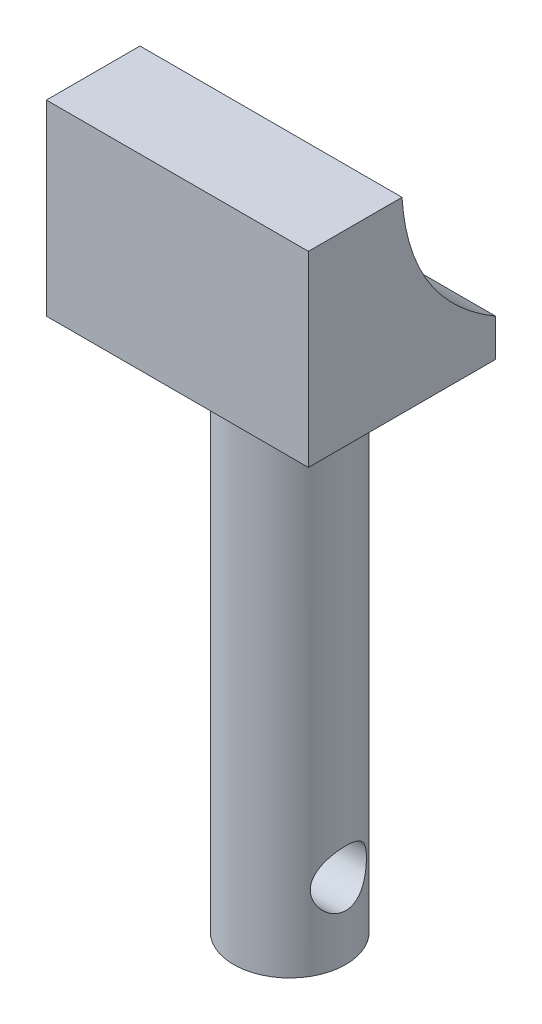
from build123d import *

# Parameters (mm, degrees)
SKETCH1_W             = 7
SKETCH1_H             = 5
BOSS_EXTRUDE1_DEPTH   = 5
CUT_EXTRUDE1_DEPTH    = 7
SKETCH4_R             = 1.5
BOSS_EXTRUDE3_DEPTH   = 14
F_1_5MM_DOWEL_HOLE2_D = 1.5


with BuildPart() as part:
    # Sketch1 → Boss-Extrude1 (new body)
    with BuildSketch(Plane.XY):
        with Locations((-1.19986884, 2.172533045)):
            Rectangle(SKETCH1_W, SKETCH1_H)
    extrude(amount=BOSS_EXTRUDE1_DEPTH)

    # Sketch2 → Cut-Extrude1 (cut)
    with BuildSketch(Plane.ZY.offset(4.69986884)):
        with BuildLine():
            Line((2.5, 4.672533045), (0, 4.672533045))
            Line((0, 4.672533045), (0, 0.672533045))
            add(Edge.make_bspline(
                [(0, 0.672533045), (2.331009943, 2.039673482), (2.5, 4.672533045)],
                knots=[0, 0, 0, 1, 1, 1], degree=2))
        make_face()
    extrude(amount=-CUT_EXTRUDE1_DEPTH, mode=Mode.SUBTRACT)

    # Sketch4 → Boss-Extrude3 (add)
    with BuildSketch(Plane.XZ.offset(0.327466955)):
        with Locations((-1.19986884, 2)):
            Circle(SKETCH4_R)
    extrude(amount=BOSS_EXTRUDE3_DEPTH)

    # Ø1.5mm Dowel Hole2 (through all)
    with Locations(Plane.ZY.offset(4.69986884)):
        with Locations((2, -12.327466955)):
            Hole(F_1_5MM_DOWEL_HOLE2_D / 2)


solid = part.part
